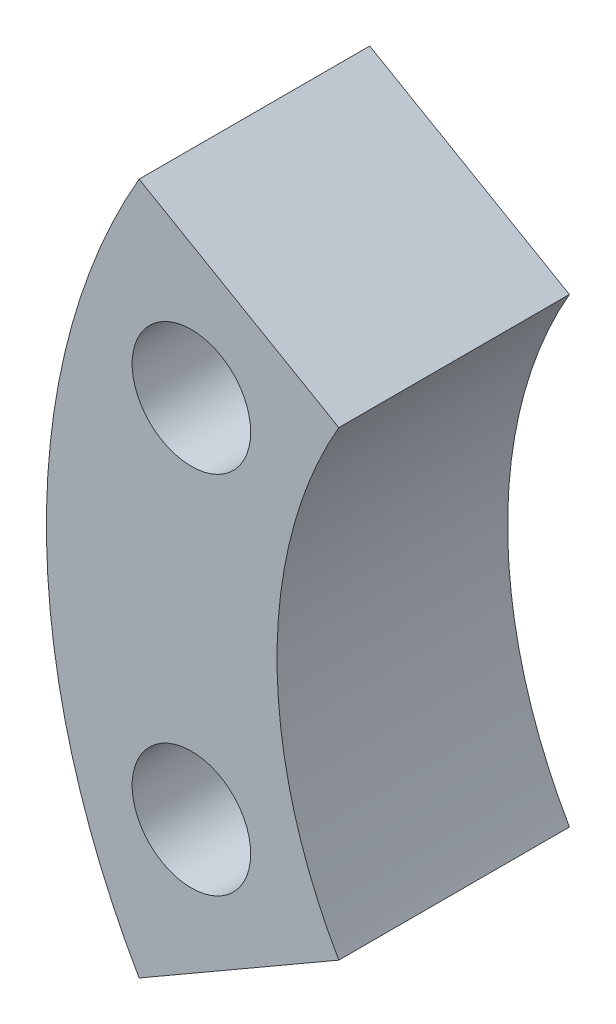
from build123d import *

# Parameters (mm, degrees)
BOSS_EXTRUDE1_DEPTH = 6.35
CUT_EXTRUDE1_REACH  = 8.35
SKETCH2_R           = 1.63195


with BuildPart() as part:
    # Sketch1 → Boss-Extrude1 (new body)
    with BuildSketch(Plane(origin=(0, 0, 0), x_dir=(0, 1, 0), z_dir=(0, 0, 1))):
        with BuildLine():
            Line((-9.525, 16.497783942), (-6.35, 10.998522628))
            ThreePointArc((-6.35, 10.998522628), (0, 12.7), (6.35, 10.998522628))
            Line((6.35, 10.998522628), (9.525, 16.497783942))
            ThreePointArc((9.525, 16.497783942), (0, 19.05), (-9.525, 16.497783942))
        make_face()
    extrude(amount=BOSS_EXTRUDE1_DEPTH)

    # Sketch2 → Cut-Extrude1 (cut, up to next)
    with BuildSketch(Plane.XY.offset(6.35), mode=Mode.PRIVATE) as cut_extrude1_sk1:
        with Locations((-15.057884182, 5.027499276)):
            Circle(SKETCH2_R)
    cut_extrude1_tool1 = extrude(cut_extrude1_sk1.sketch, amount=-CUT_EXTRUDE1_REACH, mode=Mode.PRIVATE) & part.part
    add(cut_extrude1_tool1.solids().sort_by_distance((-15.057884, 5.027499, 6.35))[0], mode=Mode.SUBTRACT)
    # Sketch2 → Cut-Extrude1 (cut, up to next)
    with BuildSketch(Plane.XY.offset(6.35), mode=Mode.PRIVATE) as cut_extrude1_sk2:
        with Locations((-15.057884182, -5.027499276)):
            Circle(SKETCH2_R)
    cut_extrude1_tool2 = extrude(cut_extrude1_sk2.sketch, amount=-CUT_EXTRUDE1_REACH, mode=Mode.PRIVATE) & part.part
    add(cut_extrude1_tool2.solids().sort_by_distance((-15.057884, -5.027499, 6.35))[0], mode=Mode.SUBTRACT)


solid = part.part
